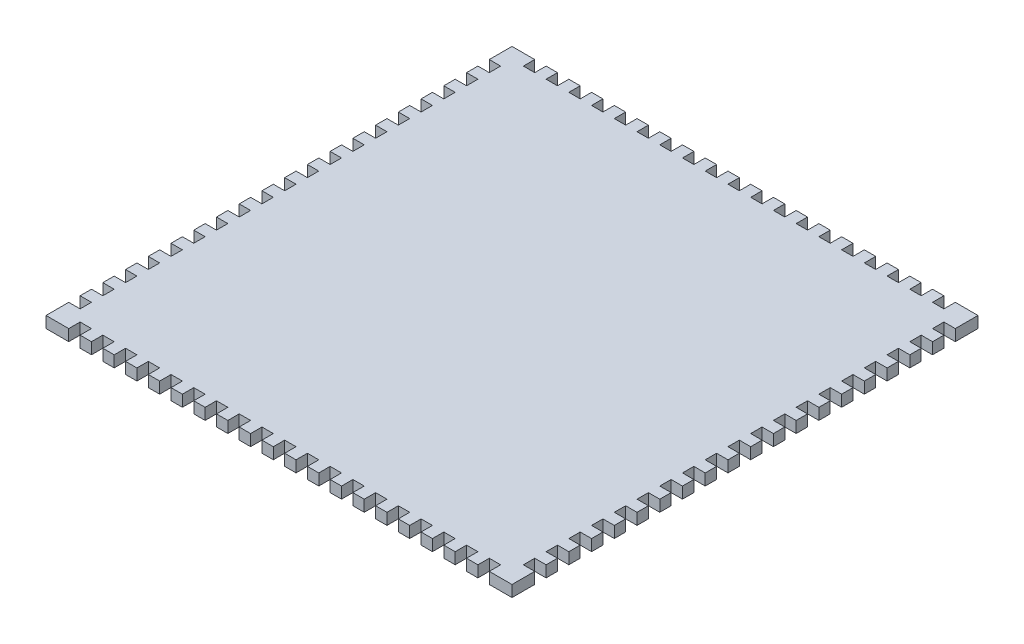
from build123d import *

# Parameters (mm, degrees)
SKETCH1_W                = 260.35
SKETCH1_H                = 260.35
BOSS_EXTRUDE1_DEPTH      = 6.35
SKETCH2_W                = 6.35
SKETCH2_H                = 6.35
CUT_EXTRUDE1_DEPTH       = 7.35
LPATTERN1_COUNT          = 19
LPATTERN1_PITCH          = 12.7
MIRROR1_COPY_1_SKETCH_W  = 6.35
MIRROR1_COPY_1_SKETCH_H  = 6.35
MIRROR1_COPY_1_DEPTH     = 7.35
MIRROR1_COPY_2_SKETCH_W  = 6.35
MIRROR1_COPY_2_SKETCH_H  = 6.35
MIRROR1_COPY_2_DEPTH     = 7.35
MIRROR1_COPY_3_SKETCH_W  = 6.35
MIRROR1_COPY_3_SKETCH_H  = 6.35
MIRROR1_COPY_3_DEPTH     = 7.35
MIRROR1_COPY_4_SKETCH_W  = 6.35
MIRROR1_COPY_4_SKETCH_H  = 6.35
MIRROR1_COPY_4_DEPTH     = 7.35
MIRROR1_COPY_5_SKETCH_W  = 6.35
MIRROR1_COPY_5_SKETCH_H  = 6.35
MIRROR1_COPY_5_DEPTH     = 7.35
MIRROR1_COPY_6_SKETCH_W  = 6.35
MIRROR1_COPY_6_SKETCH_H  = 6.35
MIRROR1_COPY_6_DEPTH     = 7.35
MIRROR1_COPY_7_SKETCH_W  = 6.35
MIRROR1_COPY_7_SKETCH_H  = 6.35
MIRROR1_COPY_7_DEPTH     = 7.35
MIRROR1_COPY_8_SKETCH_W  = 6.35
MIRROR1_COPY_8_SKETCH_H  = 6.35
MIRROR1_COPY_8_DEPTH     = 7.35
MIRROR1_COPY_9_SKETCH_W  = 6.35
MIRROR1_COPY_9_SKETCH_H  = 6.35
MIRROR1_COPY_9_DEPTH     = 7.35
MIRROR1_COPY_10_SKETCH_W = 6.35
MIRROR1_COPY_10_SKETCH_H = 6.35
MIRROR1_COPY_10_DEPTH    = 7.35
MIRROR1_COPY_11_SKETCH_W = 6.35
MIRROR1_COPY_11_SKETCH_H = 6.35
MIRROR1_COPY_11_DEPTH    = 7.35
MIRROR1_COPY_12_SKETCH_W = 6.35
MIRROR1_COPY_12_SKETCH_H = 6.35
MIRROR1_COPY_12_DEPTH    = 7.35
MIRROR1_COPY_13_SKETCH_W = 6.35
MIRROR1_COPY_13_SKETCH_H = 6.35
MIRROR1_COPY_13_DEPTH    = 7.35
MIRROR1_COPY_14_SKETCH_W = 6.35
MIRROR1_COPY_14_SKETCH_H = 6.35
MIRROR1_COPY_14_DEPTH    = 7.35
MIRROR1_COPY_15_SKETCH_W = 6.35
MIRROR1_COPY_15_SKETCH_H = 6.35
MIRROR1_COPY_15_DEPTH    = 7.35
MIRROR1_COPY_16_SKETCH_W = 6.35
MIRROR1_COPY_16_SKETCH_H = 6.35
MIRROR1_COPY_16_DEPTH    = 7.35
MIRROR1_COPY_17_SKETCH_W = 6.35
MIRROR1_COPY_17_SKETCH_H = 6.35
MIRROR1_COPY_17_DEPTH    = 7.35
MIRROR1_COPY_18_SKETCH_W = 6.35
MIRROR1_COPY_18_SKETCH_H = 6.35
MIRROR1_COPY_18_DEPTH    = 7.35
SKETCH3_W                = 6.35
SKETCH3_H                = 6.35
CUT_EXTRUDE2_DEPTH       = 7.35
LPATTERN2_COUNT          = 19
LPATTERN2_PITCH          = 12.7
MIRROR2_COPY_1_SKETCH_W  = 6.35
MIRROR2_COPY_1_SKETCH_H  = 6.35
MIRROR2_COPY_1_DEPTH     = 7.35
MIRROR2_COPY_2_SKETCH_W  = 6.35
MIRROR2_COPY_2_SKETCH_H  = 6.35
MIRROR2_COPY_2_DEPTH     = 7.35
MIRROR2_COPY_3_SKETCH_W  = 6.35
MIRROR2_COPY_3_SKETCH_H  = 6.35
MIRROR2_COPY_3_DEPTH     = 7.35
MIRROR2_COPY_4_SKETCH_W  = 6.35
MIRROR2_COPY_4_SKETCH_H  = 6.35
MIRROR2_COPY_4_DEPTH     = 7.35
MIRROR2_COPY_5_SKETCH_W  = 6.35
MIRROR2_COPY_5_SKETCH_H  = 6.35
MIRROR2_COPY_5_DEPTH     = 7.35
MIRROR2_COPY_6_SKETCH_W  = 6.35
MIRROR2_COPY_6_SKETCH_H  = 6.35
MIRROR2_COPY_6_DEPTH     = 7.35
MIRROR2_COPY_7_SKETCH_W  = 6.35
MIRROR2_COPY_7_SKETCH_H  = 6.35
MIRROR2_COPY_7_DEPTH     = 7.35
MIRROR2_COPY_8_SKETCH_W  = 6.35
MIRROR2_COPY_8_SKETCH_H  = 6.35
MIRROR2_COPY_8_DEPTH     = 7.35
MIRROR2_COPY_9_SKETCH_W  = 6.35
MIRROR2_COPY_9_SKETCH_H  = 6.35
MIRROR2_COPY_9_DEPTH     = 7.35
MIRROR2_COPY_10_SKETCH_W = 6.35
MIRROR2_COPY_10_SKETCH_H = 6.35
MIRROR2_COPY_10_DEPTH    = 7.35
MIRROR2_COPY_11_SKETCH_W = 6.35
MIRROR2_COPY_11_SKETCH_H = 6.35
MIRROR2_COPY_11_DEPTH    = 7.35
MIRROR2_COPY_12_SKETCH_W = 6.35
MIRROR2_COPY_12_SKETCH_H = 6.35
MIRROR2_COPY_12_DEPTH    = 7.35
MIRROR2_COPY_13_SKETCH_W = 6.35
MIRROR2_COPY_13_SKETCH_H = 6.35
MIRROR2_COPY_13_DEPTH    = 7.35
MIRROR2_COPY_14_SKETCH_W = 6.35
MIRROR2_COPY_14_SKETCH_H = 6.35
MIRROR2_COPY_14_DEPTH    = 7.35
MIRROR2_COPY_15_SKETCH_W = 6.35
MIRROR2_COPY_15_SKETCH_H = 6.35
MIRROR2_COPY_15_DEPTH    = 7.35
MIRROR2_COPY_16_SKETCH_W = 6.35
MIRROR2_COPY_16_SKETCH_H = 6.35
MIRROR2_COPY_16_DEPTH    = 7.35
MIRROR2_COPY_17_SKETCH_W = 6.35
MIRROR2_COPY_17_SKETCH_H = 6.35
MIRROR2_COPY_17_DEPTH    = 7.35
MIRROR2_COPY_18_SKETCH_W = 6.35
MIRROR2_COPY_18_SKETCH_H = 6.35
MIRROR2_COPY_18_DEPTH    = 7.35


with BuildPart() as part:
    # Sketch1 → Boss-Extrude1 (new body)
    with BuildSketch(Plane(origin=(0, 0, 0), x_dir=(1, 0, 0), z_dir=(0, 1, 0))):
        Rectangle(SKETCH1_W, SKETCH1_H)
    extrude(amount=BOSS_EXTRUDE1_DEPTH)

    # Sketch2 → Cut-Extrude1 (cut, through all)
    with BuildSketch(Plane(origin=(0, 6.35, 0), x_dir=(1, 0, 0), z_dir=(0, 1, 0))):
        with Locations((-114.3, 127)):
            Rectangle(SKETCH2_W, SKETCH2_H)
    cut_extrude1 = extrude(amount=-CUT_EXTRUDE1_DEPTH, mode=Mode.SUBTRACT)

    # LPattern1: Cut-Extrude1 ×19
    with Locations(*[(i * LPATTERN1_PITCH, 0, 0) for i in range(1, LPATTERN1_COUNT)]):
        add(cut_extrude1, mode=Mode.SUBTRACT)

    # Mirror1: Cut-Extrude1 across plane
    add(cut_extrude1.mirror(Plane.XY), mode=Mode.SUBTRACT)

    # Mirror1 copy 1 sketch → Mirror1 copy 1 (cut, through all)
    with BuildSketch(Plane(origin=(12.7, 6.35, 0), x_dir=(1, 0, 0), z_dir=(0, 1, 0))):
        with Locations((-114.3, -127)):
            Rectangle(MIRROR1_COPY_1_SKETCH_W, MIRROR1_COPY_1_SKETCH_H)
    extrude(amount=-MIRROR1_COPY_1_DEPTH, mode=Mode.SUBTRACT)

    # Mirror1 copy 2 sketch → Mirror1 copy 2 (cut, through all)
    with BuildSketch(Plane(origin=(25.4, 6.35, 0), x_dir=(1, 0, 0), z_dir=(0, 1, 0))):
        with Locations((-114.3, -127)):
            Rectangle(MIRROR1_COPY_2_SKETCH_W, MIRROR1_COPY_2_SKETCH_H)
    extrude(amount=-MIRROR1_COPY_2_DEPTH, mode=Mode.SUBTRACT)

    # Mirror1 copy 3 sketch → Mirror1 copy 3 (cut, through all)
    with BuildSketch(Plane(origin=(38.1, 6.35, 0), x_dir=(1, 0, 0), z_dir=(0, 1, 0))):
        with Locations((-114.3, -127)):
            Rectangle(MIRROR1_COPY_3_SKETCH_W, MIRROR1_COPY_3_SKETCH_H)
    extrude(amount=-MIRROR1_COPY_3_DEPTH, mode=Mode.SUBTRACT)

    # Mirror1 copy 4 sketch → Mirror1 copy 4 (cut, through all)
    with BuildSketch(Plane(origin=(50.8, 6.35, 0), x_dir=(1, 0, 0), z_dir=(0, 1, 0))):
        with Locations((-114.3, -127)):
            Rectangle(MIRROR1_COPY_4_SKETCH_W, MIRROR1_COPY_4_SKETCH_H)
    extrude(amount=-MIRROR1_COPY_4_DEPTH, mode=Mode.SUBTRACT)

    # Mirror1 copy 5 sketch → Mirror1 copy 5 (cut, through all)
    with BuildSketch(Plane(origin=(63.5, 6.35, 0), x_dir=(1, 0, 0), z_dir=(0, 1, 0))):
        with Locations((-114.3, -127)):
            Rectangle(MIRROR1_COPY_5_SKETCH_W, MIRROR1_COPY_5_SKETCH_H)
    extrude(amount=-MIRROR1_COPY_5_DEPTH, mode=Mode.SUBTRACT)

    # Mirror1 copy 6 sketch → Mirror1 copy 6 (cut, through all)
    with BuildSketch(Plane(origin=(76.2, 6.35, 0), x_dir=(1, 0, 0), z_dir=(0, 1, 0))):
        with Locations((-114.3, -127)):
            Rectangle(MIRROR1_COPY_6_SKETCH_W, MIRROR1_COPY_6_SKETCH_H)
    extrude(amount=-MIRROR1_COPY_6_DEPTH, mode=Mode.SUBTRACT)

    # Mirror1 copy 7 sketch → Mirror1 copy 7 (cut, through all)
    with BuildSketch(Plane(origin=(88.9, 6.35, 0), x_dir=(1, 0, 0), z_dir=(0, 1, 0))):
        with Locations((-114.3, -127)):
            Rectangle(MIRROR1_COPY_7_SKETCH_W, MIRROR1_COPY_7_SKETCH_H)
    extrude(amount=-MIRROR1_COPY_7_DEPTH, mode=Mode.SUBTRACT)

    # Mirror1 copy 8 sketch → Mirror1 copy 8 (cut, through all)
    with BuildSketch(Plane(origin=(101.6, 6.35, 0), x_dir=(1, 0, 0), z_dir=(0, 1, 0))):
        with Locations((-114.3, -127)):
            Rectangle(MIRROR1_COPY_8_SKETCH_W, MIRROR1_COPY_8_SKETCH_H)
    extrude(amount=-MIRROR1_COPY_8_DEPTH, mode=Mode.SUBTRACT)

    # Mirror1 copy 9 sketch → Mirror1 copy 9 (cut, through all)
    with BuildSketch(Plane(origin=(114.3, 6.35, 0), x_dir=(1, 0, 0), z_dir=(0, 1, 0))):
        with Locations((-114.3, -127)):
            Rectangle(MIRROR1_COPY_9_SKETCH_W, MIRROR1_COPY_9_SKETCH_H)
    extrude(amount=-MIRROR1_COPY_9_DEPTH, mode=Mode.SUBTRACT)

    # Mirror1 copy 10 sketch → Mirror1 copy 10 (cut, through all)
    with BuildSketch(Plane(origin=(127, 6.35, 0), x_dir=(1, 0, 0), z_dir=(0, 1, 0))):
        with Locations((-114.3, -127)):
            Rectangle(MIRROR1_COPY_10_SKETCH_W, MIRROR1_COPY_10_SKETCH_H)
    extrude(amount=-MIRROR1_COPY_10_DEPTH, mode=Mode.SUBTRACT)

    # Mirror1 copy 11 sketch → Mirror1 copy 11 (cut, through all)
    with BuildSketch(Plane(origin=(139.7, 6.35, 0), x_dir=(1, 0, 0), z_dir=(0, 1, 0))):
        with Locations((-114.3, -127)):
            Rectangle(MIRROR1_COPY_11_SKETCH_W, MIRROR1_COPY_11_SKETCH_H)
    extrude(amount=-MIRROR1_COPY_11_DEPTH, mode=Mode.SUBTRACT)

    # Mirror1 copy 12 sketch → Mirror1 copy 12 (cut, through all)
    with BuildSketch(Plane(origin=(152.4, 6.35, 0), x_dir=(1, 0, 0), z_dir=(0, 1, 0))):
        with Locations((-114.3, -127)):
            Rectangle(MIRROR1_COPY_12_SKETCH_W, MIRROR1_COPY_12_SKETCH_H)
    extrude(amount=-MIRROR1_COPY_12_DEPTH, mode=Mode.SUBTRACT)

    # Mirror1 copy 13 sketch → Mirror1 copy 13 (cut, through all)
    with BuildSketch(Plane(origin=(165.1, 6.35, 0), x_dir=(1, 0, 0), z_dir=(0, 1, 0))):
        with Locations((-114.3, -127)):
            Rectangle(MIRROR1_COPY_13_SKETCH_W, MIRROR1_COPY_13_SKETCH_H)
    extrude(amount=-MIRROR1_COPY_13_DEPTH, mode=Mode.SUBTRACT)

    # Mirror1 copy 14 sketch → Mirror1 copy 14 (cut, through all)
    with BuildSketch(Plane(origin=(177.8, 6.35, 0), x_dir=(1, 0, 0), z_dir=(0, 1, 0))):
        with Locations((-114.3, -127)):
            Rectangle(MIRROR1_COPY_14_SKETCH_W, MIRROR1_COPY_14_SKETCH_H)
    extrude(amount=-MIRROR1_COPY_14_DEPTH, mode=Mode.SUBTRACT)

    # Mirror1 copy 15 sketch → Mirror1 copy 15 (cut, through all)
    with BuildSketch(Plane(origin=(190.5, 6.35, 0), x_dir=(1, 0, 0), z_dir=(0, 1, 0))):
        with Locations((-114.3, -127)):
            Rectangle(MIRROR1_COPY_15_SKETCH_W, MIRROR1_COPY_15_SKETCH_H)
    extrude(amount=-MIRROR1_COPY_15_DEPTH, mode=Mode.SUBTRACT)

    # Mirror1 copy 16 sketch → Mirror1 copy 16 (cut, through all)
    with BuildSketch(Plane(origin=(203.2, 6.35, 0), x_dir=(1, 0, 0), z_dir=(0, 1, 0))):
        with Locations((-114.3, -127)):
            Rectangle(MIRROR1_COPY_16_SKETCH_W, MIRROR1_COPY_16_SKETCH_H)
    extrude(amount=-MIRROR1_COPY_16_DEPTH, mode=Mode.SUBTRACT)

    # Mirror1 copy 17 sketch → Mirror1 copy 17 (cut, through all)
    with BuildSketch(Plane(origin=(215.9, 6.35, 0), x_dir=(1, 0, 0), z_dir=(0, 1, 0))):
        with Locations((-114.3, -127)):
            Rectangle(MIRROR1_COPY_17_SKETCH_W, MIRROR1_COPY_17_SKETCH_H)
    extrude(amount=-MIRROR1_COPY_17_DEPTH, mode=Mode.SUBTRACT)

    # Mirror1 copy 18 sketch → Mirror1 copy 18 (cut, through all)
    with BuildSketch(Plane(origin=(228.6, 6.35, 0), x_dir=(1, 0, 0), z_dir=(0, 1, 0))):
        with Locations((-114.3, -127)):
            Rectangle(MIRROR1_COPY_18_SKETCH_W, MIRROR1_COPY_18_SKETCH_H)
    extrude(amount=-MIRROR1_COPY_18_DEPTH, mode=Mode.SUBTRACT)

    # Sketch3 → Cut-Extrude2 (cut, through all)
    with BuildSketch(Plane(origin=(0, 6.35, 0), x_dir=(1, 0, 0), z_dir=(0, 1, 0))):
        with Locations((-127, 114.3)):
            Rectangle(SKETCH3_W, SKETCH3_H)
    cut_extrude2 = extrude(amount=-CUT_EXTRUDE2_DEPTH, mode=Mode.SUBTRACT)

    # LPattern2: Cut-Extrude2 ×19
    with Locations(*[(0, 0, i * LPATTERN2_PITCH) for i in range(1, LPATTERN2_COUNT)]):
        add(cut_extrude2, mode=Mode.SUBTRACT)

    # Mirror2: Cut-Extrude2 across plane
    add(cut_extrude2.mirror(Plane(origin=(0, 0, 0), x_dir=(0, 0, 1), z_dir=(1, 0, 0))), mode=Mode.SUBTRACT)

    # Mirror2 copy 1 sketch → Mirror2 copy 1 (cut, through all)
    with BuildSketch(Plane(origin=(0, 6.35, 12.7), x_dir=(-1, 0, 0), z_dir=(0, 1, 0))):
        with Locations((-127, -114.3)):
            Rectangle(MIRROR2_COPY_1_SKETCH_W, MIRROR2_COPY_1_SKETCH_H)
    extrude(amount=-MIRROR2_COPY_1_DEPTH, mode=Mode.SUBTRACT)

    # Mirror2 copy 2 sketch → Mirror2 copy 2 (cut, through all)
    with BuildSketch(Plane(origin=(0, 6.35, 25.4), x_dir=(-1, 0, 0), z_dir=(0, 1, 0))):
        with Locations((-127, -114.3)):
            Rectangle(MIRROR2_COPY_2_SKETCH_W, MIRROR2_COPY_2_SKETCH_H)
    extrude(amount=-MIRROR2_COPY_2_DEPTH, mode=Mode.SUBTRACT)

    # Mirror2 copy 3 sketch → Mirror2 copy 3 (cut, through all)
    with BuildSketch(Plane(origin=(0, 6.35, 38.1), x_dir=(-1, 0, 0), z_dir=(0, 1, 0))):
        with Locations((-127, -114.3)):
            Rectangle(MIRROR2_COPY_3_SKETCH_W, MIRROR2_COPY_3_SKETCH_H)
    extrude(amount=-MIRROR2_COPY_3_DEPTH, mode=Mode.SUBTRACT)

    # Mirror2 copy 4 sketch → Mirror2 copy 4 (cut, through all)
    with BuildSketch(Plane(origin=(0, 6.35, 50.8), x_dir=(-1, 0, 0), z_dir=(0, 1, 0))):
        with Locations((-127, -114.3)):
            Rectangle(MIRROR2_COPY_4_SKETCH_W, MIRROR2_COPY_4_SKETCH_H)
    extrude(amount=-MIRROR2_COPY_4_DEPTH, mode=Mode.SUBTRACT)

    # Mirror2 copy 5 sketch → Mirror2 copy 5 (cut, through all)
    with BuildSketch(Plane(origin=(0, 6.35, 63.5), x_dir=(-1, 0, 0), z_dir=(0, 1, 0))):
        with Locations((-127, -114.3)):
            Rectangle(MIRROR2_COPY_5_SKETCH_W, MIRROR2_COPY_5_SKETCH_H)
    extrude(amount=-MIRROR2_COPY_5_DEPTH, mode=Mode.SUBTRACT)

    # Mirror2 copy 6 sketch → Mirror2 copy 6 (cut, through all)
    with BuildSketch(Plane(origin=(0, 6.35, 76.2), x_dir=(-1, 0, 0), z_dir=(0, 1, 0))):
        with Locations((-127, -114.3)):
            Rectangle(MIRROR2_COPY_6_SKETCH_W, MIRROR2_COPY_6_SKETCH_H)
    extrude(amount=-MIRROR2_COPY_6_DEPTH, mode=Mode.SUBTRACT)

    # Mirror2 copy 7 sketch → Mirror2 copy 7 (cut, through all)
    with BuildSketch(Plane(origin=(0, 6.35, 88.9), x_dir=(-1, 0, 0), z_dir=(0, 1, 0))):
        with Locations((-127, -114.3)):
            Rectangle(MIRROR2_COPY_7_SKETCH_W, MIRROR2_COPY_7_SKETCH_H)
    extrude(amount=-MIRROR2_COPY_7_DEPTH, mode=Mode.SUBTRACT)

    # Mirror2 copy 8 sketch → Mirror2 copy 8 (cut, through all)
    with BuildSketch(Plane(origin=(0, 6.35, 101.6), x_dir=(-1, 0, 0), z_dir=(0, 1, 0))):
        with Locations((-127, -114.3)):
            Rectangle(MIRROR2_COPY_8_SKETCH_W, MIRROR2_COPY_8_SKETCH_H)
    extrude(amount=-MIRROR2_COPY_8_DEPTH, mode=Mode.SUBTRACT)

    # Mirror2 copy 9 sketch → Mirror2 copy 9 (cut, through all)
    with BuildSketch(Plane(origin=(0, 6.35, 114.3), x_dir=(-1, 0, 0), z_dir=(0, 1, 0))):
        with Locations((-127, -114.3)):
            Rectangle(MIRROR2_COPY_9_SKETCH_W, MIRROR2_COPY_9_SKETCH_H)
    extrude(amount=-MIRROR2_COPY_9_DEPTH, mode=Mode.SUBTRACT)

    # Mirror2 copy 10 sketch → Mirror2 copy 10 (cut, through all)
    with BuildSketch(Plane(origin=(0, 6.35, 127), x_dir=(-1, 0, 0), z_dir=(0, 1, 0))):
        with Locations((-127, -114.3)):
            Rectangle(MIRROR2_COPY_10_SKETCH_W, MIRROR2_COPY_10_SKETCH_H)
    extrude(amount=-MIRROR2_COPY_10_DEPTH, mode=Mode.SUBTRACT)

    # Mirror2 copy 11 sketch → Mirror2 copy 11 (cut, through all)
    with BuildSketch(Plane(origin=(0, 6.35, 139.7), x_dir=(-1, 0, 0), z_dir=(0, 1, 0))):
        with Locations((-127, -114.3)):
            Rectangle(MIRROR2_COPY_11_SKETCH_W, MIRROR2_COPY_11_SKETCH_H)
    extrude(amount=-MIRROR2_COPY_11_DEPTH, mode=Mode.SUBTRACT)

    # Mirror2 copy 12 sketch → Mirror2 copy 12 (cut, through all)
    with BuildSketch(Plane(origin=(0, 6.35, 152.4), x_dir=(-1, 0, 0), z_dir=(0, 1, 0))):
        with Locations((-127, -114.3)):
            Rectangle(MIRROR2_COPY_12_SKETCH_W, MIRROR2_COPY_12_SKETCH_H)
    extrude(amount=-MIRROR2_COPY_12_DEPTH, mode=Mode.SUBTRACT)

    # Mirror2 copy 13 sketch → Mirror2 copy 13 (cut, through all)
    with BuildSketch(Plane(origin=(0, 6.35, 165.1), x_dir=(-1, 0, 0), z_dir=(0, 1, 0))):
        with Locations((-127, -114.3)):
            Rectangle(MIRROR2_COPY_13_SKETCH_W, MIRROR2_COPY_13_SKETCH_H)
    extrude(amount=-MIRROR2_COPY_13_DEPTH, mode=Mode.SUBTRACT)

    # Mirror2 copy 14 sketch → Mirror2 copy 14 (cut, through all)
    with BuildSketch(Plane(origin=(0, 6.35, 177.8), x_dir=(-1, 0, 0), z_dir=(0, 1, 0))):
        with Locations((-127, -114.3)):
            Rectangle(MIRROR2_COPY_14_SKETCH_W, MIRROR2_COPY_14_SKETCH_H)
    extrude(amount=-MIRROR2_COPY_14_DEPTH, mode=Mode.SUBTRACT)

    # Mirror2 copy 15 sketch → Mirror2 copy 15 (cut, through all)
    with BuildSketch(Plane(origin=(0, 6.35, 190.5), x_dir=(-1, 0, 0), z_dir=(0, 1, 0))):
        with Locations((-127, -114.3)):
            Rectangle(MIRROR2_COPY_15_SKETCH_W, MIRROR2_COPY_15_SKETCH_H)
    extrude(amount=-MIRROR2_COPY_15_DEPTH, mode=Mode.SUBTRACT)

    # Mirror2 copy 16 sketch → Mirror2 copy 16 (cut, through all)
    with BuildSketch(Plane(origin=(0, 6.35, 203.2), x_dir=(-1, 0, 0), z_dir=(0, 1, 0))):
        with Locations((-127, -114.3)):
            Rectangle(MIRROR2_COPY_16_SKETCH_W, MIRROR2_COPY_16_SKETCH_H)
    extrude(amount=-MIRROR2_COPY_16_DEPTH, mode=Mode.SUBTRACT)

    # Mirror2 copy 17 sketch → Mirror2 copy 17 (cut, through all)
    with BuildSketch(Plane(origin=(0, 6.35, 215.9), x_dir=(-1, 0, 0), z_dir=(0, 1, 0))):
        with Locations((-127, -114.3)):
            Rectangle(MIRROR2_COPY_17_SKETCH_W, MIRROR2_COPY_17_SKETCH_H)
    extrude(amount=-MIRROR2_COPY_17_DEPTH, mode=Mode.SUBTRACT)

    # Mirror2 copy 18 sketch → Mirror2 copy 18 (cut, through all)
    with BuildSketch(Plane(origin=(0, 6.35, 228.6), x_dir=(-1, 0, 0), z_dir=(0, 1, 0))):
        with Locations((-127, -114.3)):
            Rectangle(MIRROR2_COPY_18_SKETCH_W, MIRROR2_COPY_18_SKETCH_H)
    extrude(amount=-MIRROR2_COPY_18_DEPTH, mode=Mode.SUBTRACT)


solid = part.part
